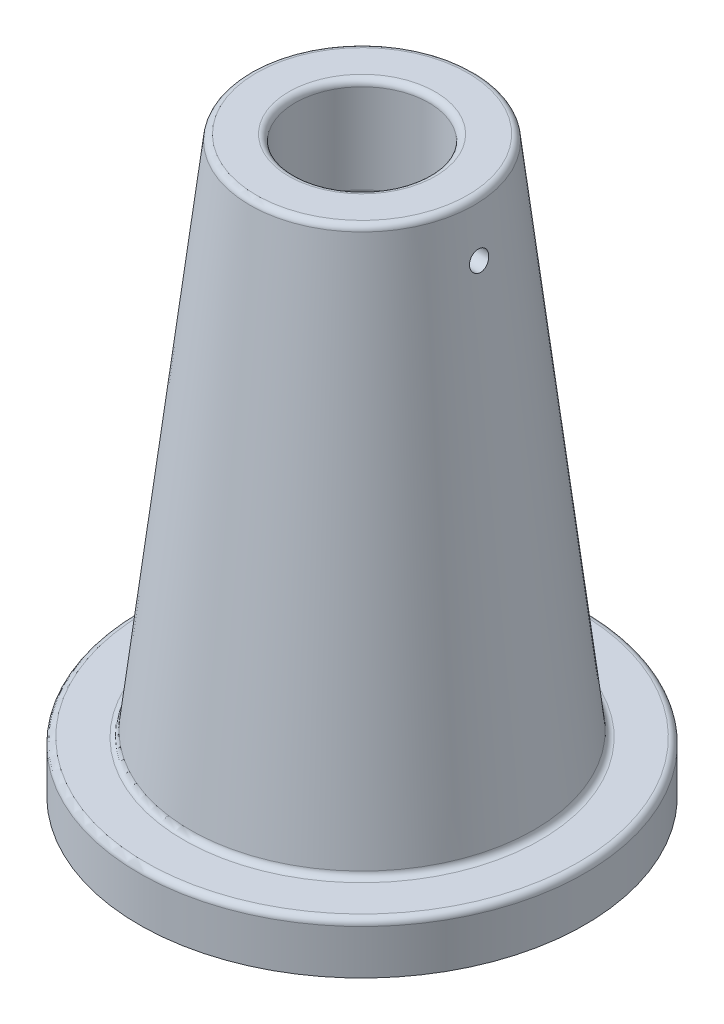
from build123d import *

# Parameters (mm, degrees)
CUT_EXTRUDE_1_REACH = 182
SKETCH_3_R          = 21
SKETCH_4_R          = 3
CUT_EXTRUDE_2_DEPTH = 71
FILLET_1_R          = 2


with BuildPart() as part:
    # 草图2 → 旋转1 (revolve)
    with BuildSketch(Plane.XY):
        Polygon((0, 180), (0, 148), (-29.682849507, 148), (-47, 0), (-70, 0), (-70, 16), (-54.189274871, 16), (-35, 180), align=None)
    revolve(axis=Axis((0, 180, 0), (0, -1, 0)))

    # 草图3 → 切除-拉伸1 (cut, up to next)
    with BuildSketch(Plane(origin=(0, 180, 0), x_dir=(1, 0, 0), z_dir=(0, 1, 0)), mode=Mode.PRIVATE) as cut_extrude_1_sk1:
        Circle(SKETCH_3_R)
    cut_extrude_1_tool1 = extrude(cut_extrude_1_sk1.sketch, amount=-CUT_EXTRUDE_1_REACH, mode=Mode.PRIVATE) & part.part
    add(cut_extrude_1_tool1.solids().sort_by_distance((0, 180, 0))[0], mode=Mode.SUBTRACT)

    # 草图4 → 切除-拉伸2 (cut, through all)
    with BuildSketch(Plane(origin=(0, 0, 0), x_dir=(0, 0, -1), z_dir=(1, 0, 0))):
        with Locations((0, 164)):
            Circle(SKETCH_4_R)
    extrude(amount=CUT_EXTRUDE_2_DEPTH, mode=Mode.SUBTRACT)

    # 圆角1
    fillet_1_edges = [part.edges().sort_by_distance(p)[0] for p in [
        (-21, 148, 0),
        (-21, 180, 0),
        (35, 180, 0),
        (54.189274871, 16, 0),
        (70, 16, 0),
        (29.682849507, 148, 0),
    ]]
    fillet(fillet_1_edges, radius=FILLET_1_R)


solid = part.part
